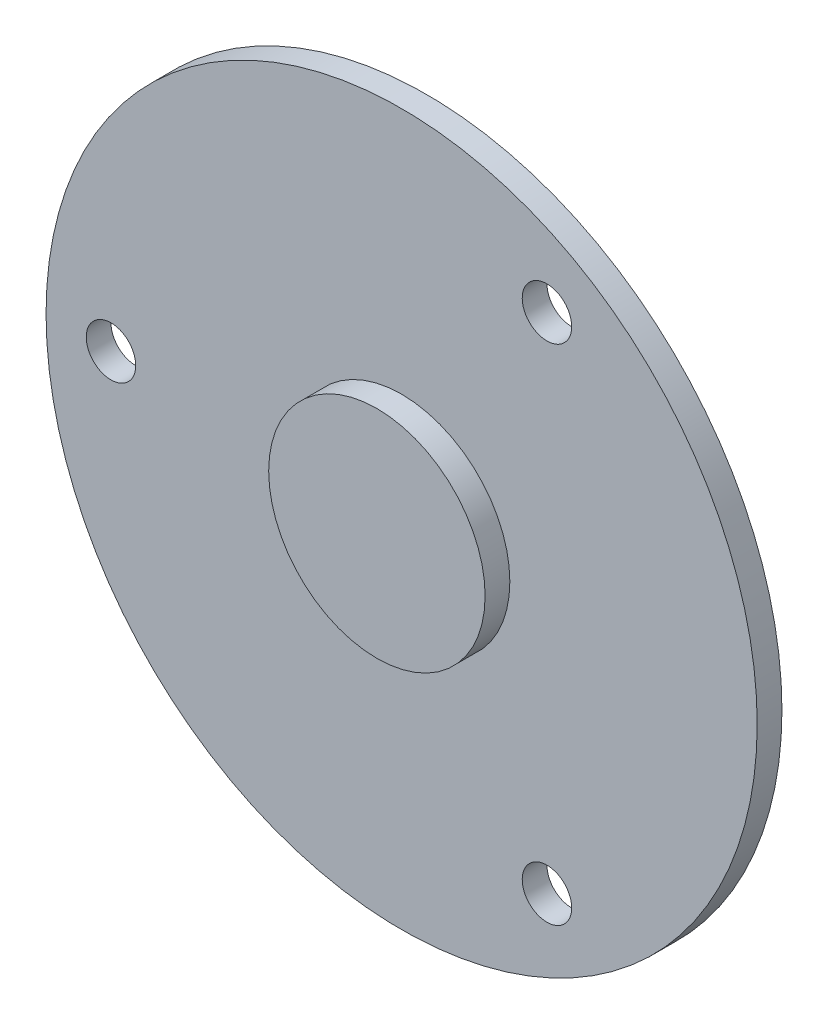
from build123d import *

# Parameters (mm, degrees)
SKETCH_1_R               = 57.5
EXTRUDE_1_DEPTH          = 4
SKETCH_2_R               = 17.5
EXTRUDE_2_DEPTH          = 4
SKETCH_3_R               = 4
CUT_EXTRUDE_1_DEPTH      = 12
PATTERN_CIRCULAR_1_COUNT = 3


with BuildPart() as part:
    # 草图1 → 凸台-拉伸1 (new body)
    with BuildSketch(Plane.XY):
        Circle(SKETCH_1_R)
    extrude(amount=EXTRUDE_1_DEPTH)

    # 草图2 → 凸台-拉伸2 (add)
    with BuildSketch(Plane.XY.offset(4)):
        Circle(SKETCH_2_R)
    extrude(amount=EXTRUDE_2_DEPTH)

    # 草图3 → 切除-拉伸1 (cut)
    with BuildSketch(Plane(origin=(0, 0, 0), x_dir=(-1, 0, 0), z_dir=(0, 0, -1))):
        with Locations((47, 0)):
            Circle(SKETCH_3_R)
    cut_extrude_1 = extrude(amount=-CUT_EXTRUDE_1_DEPTH, mode=Mode.SUBTRACT)

    # 阵列(圆周)1: 切除-拉伸1 ×3 about axis
    pattern_circular_1_axis = Axis((0, 0, 0), (0, 0, 1))
    for i in range(1, PATTERN_CIRCULAR_1_COUNT):
        add(cut_extrude_1.rotate(pattern_circular_1_axis, i * 360 / PATTERN_CIRCULAR_1_COUNT), mode=Mode.SUBTRACT)


solid = part.part
